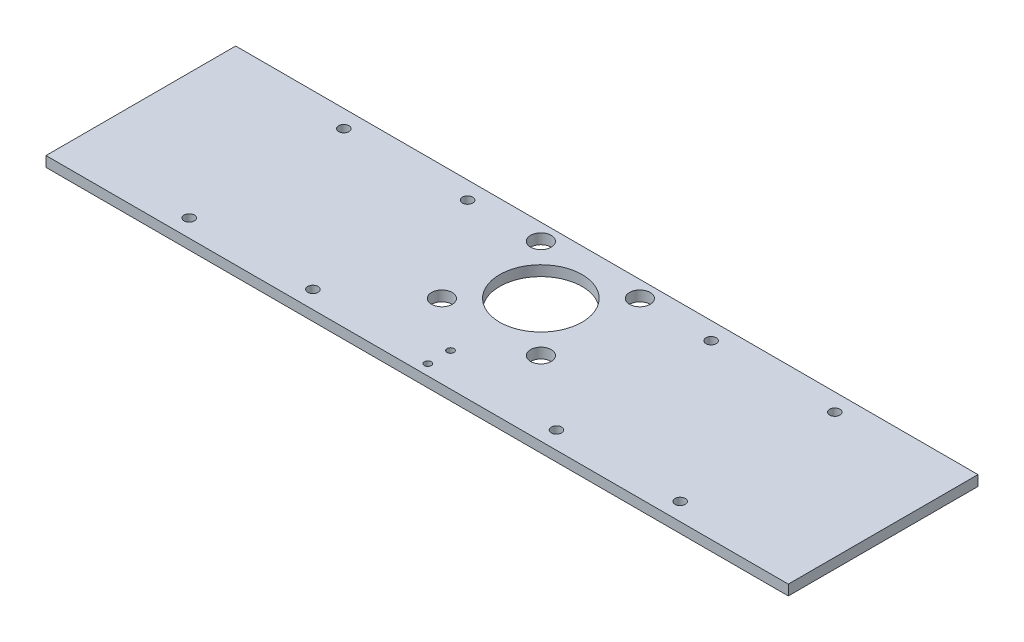
from build123d import *

# Parameters (mm, degrees)
SKETCH1_W                   = 457.2
SKETCH1_H                   = 116.84
BOSS_EXTRUDE1_DEPTH         = 3.175
F_1_1_DIAMETER_HOLE1_D      = 50.8
F_1_2_0_5_DIAMETER_HOLE1_D  = 12.7
F_4_0_4_DIAMETER_HOLE1_D    = 4.2164
F_1_4_0_25_DIAMETER_HOLE1_D = 6.35
AUX_CLEARANCE_HOLES_REACH   = 8.35
SKETCH11_R                  = 3.175


with BuildPart() as part:
    # Sketch1 → Boss-Extrude1 (new body, symmetric)
    with BuildSketch(Plane(origin=(0, 0, 0), x_dir=(1, 0, 0), z_dir=(0, 1, 0))):
        with Locations((0, -17.78)):
            Rectangle(SKETCH1_W, SKETCH1_H)
    extrude(amount=BOSS_EXTRUDE1_DEPTH, both=True)

    # 1 (1) Diameter Hole1 (through all)
    with Locations(Plane(origin=(0, 3.175, 0), x_dir=(1, 0, 0), z_dir=(0, 1, 0))):
        with Locations((0, 0)):
            Hole(F_1_1_DIAMETER_HOLE1_D / 2)

    # 1/2 (0.5) Diameter Hole1 (through all)
    with Locations(Plane(origin=(0, 3.175, 0), x_dir=(1, 0, 0), z_dir=(0, 1, 0))):
        with Locations((30.48, -30.48), (-30.48, 30.48), (-30.48, -30.48), (30.48, 30.48)):
            Hole(F_1_2_0_5_DIAMETER_HOLE1_D / 2)

    # Ø4.0 (4) Diameter Hole1 (through all)
    with Locations(Plane(origin=(0, 3.175, 0), x_dir=(1, 0, 0), z_dir=(0, 1, 0))):
        with Locations((0, -55.63), (0, -69.63)):
            Hole(F_4_0_4_DIAMETER_HOLE1_D / 2)

    # 1/4 (0.25) Diameter Hole1 (through all)
    with Locations(Plane(origin=(0, 3.175, 0), x_dir=(1, 0, 0), z_dir=(0, 1, 0))):
        with Locations((75, -65.405), (-75, 29.845), (-75, -65.405), (75, 29.845)):
            Hole(F_1_4_0_25_DIAMETER_HOLE1_D / 2)

    # Sketch11 → Aux Clearance holes (cut, up to next)
    with BuildSketch(Plane(origin=(0, 3.175, 0), x_dir=(1, 0, 0), z_dir=(0, 1, 0)), mode=Mode.PRIVATE) as aux_clearance_holes_sk1:
        with Locations((-151.2, 29.845)):
            Circle(SKETCH11_R)
    aux_clearance_holes_tool1 = extrude(aux_clearance_holes_sk1.sketch, amount=-AUX_CLEARANCE_HOLES_REACH, mode=Mode.PRIVATE) & part.part
    add(aux_clearance_holes_tool1.solids().sort_by_distance((-151.2, 3.175, -29.845))[0], mode=Mode.SUBTRACT)
    # Sketch11 → Aux Clearance holes (cut, up to next)
    with BuildSketch(Plane(origin=(0, 3.175, 0), x_dir=(1, 0, 0), z_dir=(0, 1, 0)), mode=Mode.PRIVATE) as aux_clearance_holes_sk2:
        with Locations((-151.2, -65.405)):
            Circle(SKETCH11_R)
    aux_clearance_holes_tool2 = extrude(aux_clearance_holes_sk2.sketch, amount=-AUX_CLEARANCE_HOLES_REACH, mode=Mode.PRIVATE) & part.part
    add(aux_clearance_holes_tool2.solids().sort_by_distance((-151.2, 3.175, 65.405))[0], mode=Mode.SUBTRACT)
    # Sketch11 → Aux Clearance holes (cut, up to next)
    with BuildSketch(Plane(origin=(0, 3.175, 0), x_dir=(1, 0, 0), z_dir=(0, 1, 0)), mode=Mode.PRIVATE) as aux_clearance_holes_sk3:
        with Locations((151.2, 29.845)):
            Circle(SKETCH11_R)
    aux_clearance_holes_tool3 = extrude(aux_clearance_holes_sk3.sketch, amount=-AUX_CLEARANCE_HOLES_REACH, mode=Mode.PRIVATE) & part.part
    add(aux_clearance_holes_tool3.solids().sort_by_distance((151.2, 3.175, -29.845))[0], mode=Mode.SUBTRACT)
    # Sketch11 → Aux Clearance holes (cut, up to next)
    with BuildSketch(Plane(origin=(0, 3.175, 0), x_dir=(1, 0, 0), z_dir=(0, 1, 0)), mode=Mode.PRIVATE) as aux_clearance_holes_sk4:
        with Locations((151.2, -65.405)):
            Circle(SKETCH11_R)
    aux_clearance_holes_tool4 = extrude(aux_clearance_holes_sk4.sketch, amount=-AUX_CLEARANCE_HOLES_REACH, mode=Mode.PRIVATE) & part.part
    add(aux_clearance_holes_tool4.solids().sort_by_distance((151.2, 3.175, 65.405))[0], mode=Mode.SUBTRACT)


solid = part.part
